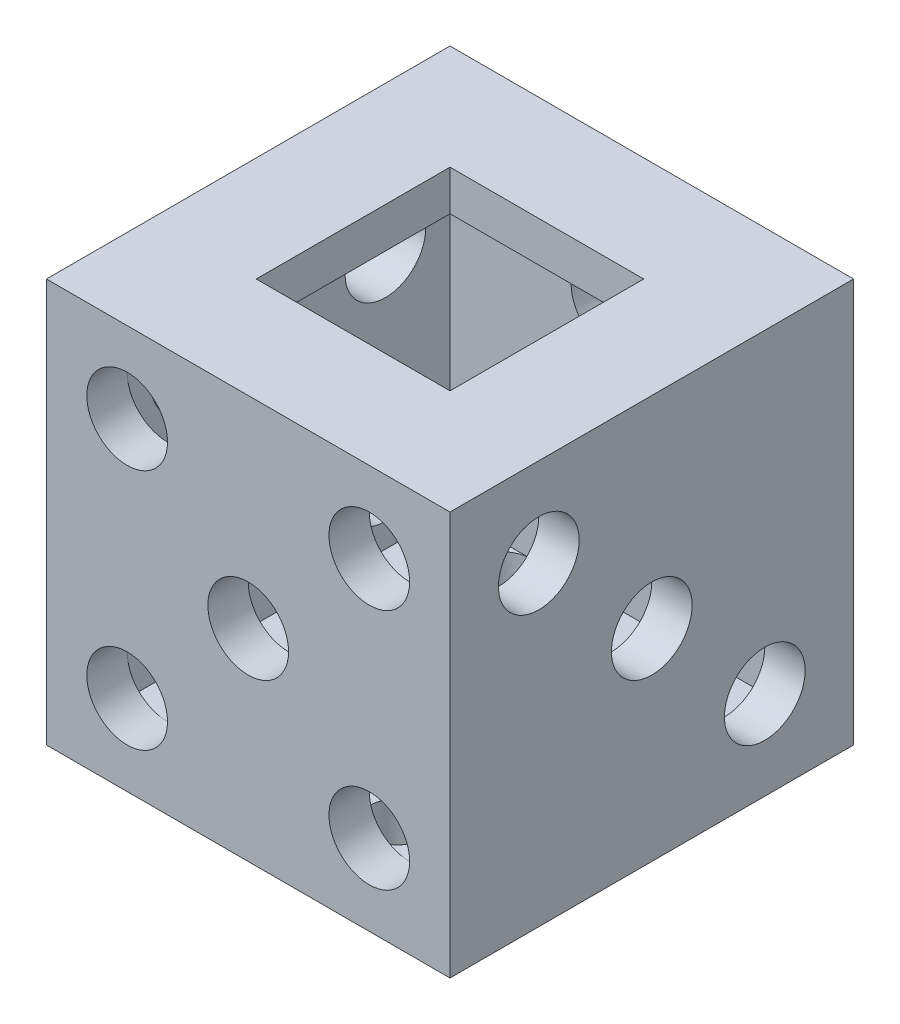
from build123d import *

# Parameters (mm, degrees)
SKETCH1_W           = 25
SKETCH1_H           = 25
BOSS_EXTRUDE1_DEPTH = 25
SHELL1_T            = 2.5
SKETCH2_W           = 12
SKETCH2_H           = 12
CUT_EXTRUDE1_DEPTH  = 15
SKETCH3_R           = 1.75
CUT_EXTRUDE2_DEPTH  = 15
SKETCH4_R           = 2.5
CUT_EXTRUDE6_DEPTH  = 15
SKETCH4_3_R         = 2.5
CUT_EXTRUDE7_DEPTH  = 15
SKETCH5_R           = 2.5
CUT_EXTRUDE8_DEPTH  = 15
SKETCH5_4_R         = 2.5
CUT_EXTRUDE9_DEPTH  = 15
SKETCH5_5_R         = 2.5
CUT_EXTRUDE10_DEPTH = 15
SKETCH7_R           = 2.5
CUT_EXTRUDE11_DEPTH = 15
SKETCH8_R           = 2.5
CUT_EXTRUDE12_DEPTH = 10


with BuildPart() as part:
    # Sketch1 → Boss-Extrude1 (new body)
    with BuildSketch(Plane(origin=(0, 0, 0), x_dir=(1, 0, 0), z_dir=(0, 1, 0))):
        Rectangle(SKETCH1_W, SKETCH1_H)
    extrude(amount=BOSS_EXTRUDE1_DEPTH)

    # Shell1 (no face opened: a closed hollow body)
    add(offset(amount=-SHELL1_T, mode=Mode.PRIVATE), mode=Mode.SUBTRACT)

    # Sketch2 → Cut-Extrude1 (cut)
    with BuildSketch(Plane(origin=(0, 25, 0), x_dir=(1, 0, 0), z_dir=(0, 1, 0))):
        Rectangle(SKETCH2_W, SKETCH2_H)
    extrude(amount=-CUT_EXTRUDE1_DEPTH, mode=Mode.SUBTRACT)

    # Sketch3 → Cut-Extrude2 (cut)
    with BuildSketch(Plane.XZ):
        with Locations((-5, 8.25)):
            Circle(SKETCH3_R)
        with Locations((-5, 0)):
            Circle(SKETCH3_R)
        with Locations((-5, -8.25)):
            Circle(SKETCH3_R)
        with Locations((5, 8.25)):
            Circle(SKETCH3_R)
        with Locations((5, 0)):
            Circle(SKETCH3_R)
        with Locations((5, -8.25)):
            Circle(SKETCH3_R)
    extrude(amount=-CUT_EXTRUDE2_DEPTH, mode=Mode.SUBTRACT)

    # Sketch4 → Cut-Extrude6 (cut)
    with BuildSketch(Plane(origin=(12.5, 0, 0), x_dir=(0, 0, -1), z_dir=(1, 0, 0))):
        with Locations((-7, 19.5)):
            Circle(SKETCH4_R)
    extrude(amount=-CUT_EXTRUDE6_DEPTH, mode=Mode.SUBTRACT)

    # Sketch4_3 → Cut-Extrude7 (cut)
    with BuildSketch(Plane(origin=(12.5, 0, 0), x_dir=(0, 0, -1), z_dir=(1, 0, 0))):
        with Locations((0, 12.5)):
            Circle(SKETCH4_3_R)
        with Locations((7, 5.5)):
            Circle(SKETCH4_3_R)
    extrude(amount=-CUT_EXTRUDE7_DEPTH, mode=Mode.SUBTRACT)

    # Sketch5 → Cut-Extrude8 (cut)
    with BuildSketch(Plane.ZY.offset(12.5)):
        with Locations((-6, 18.5)):
            Circle(SKETCH5_R)
    extrude(amount=-CUT_EXTRUDE8_DEPTH, mode=Mode.SUBTRACT)

    # Sketch5_4 → Cut-Extrude9 (cut)
    with BuildSketch(Plane.ZY.offset(12.5)):
        with Locations((6, 18.5)):
            Circle(SKETCH5_4_R)
    extrude(amount=-CUT_EXTRUDE9_DEPTH, mode=Mode.SUBTRACT)

    # Sketch5_5 → Cut-Extrude10 (cut)
    with BuildSketch(Plane.ZY.offset(12.5)):
        with Locations((6, 6.5)):
            Circle(SKETCH5_5_R)
        with Locations((-6, 6.5)):
            Circle(SKETCH5_5_R)
    extrude(amount=-CUT_EXTRUDE10_DEPTH, mode=Mode.SUBTRACT)

    # Sketch7 → Cut-Extrude11 (cut)
    with BuildSketch(Plane.XY.offset(12.5)):
        with Locations((-7.5, 20)):
            Circle(SKETCH7_R)
        with Locations((0, 12.5)):
            Circle(SKETCH7_R)
        with Locations((7.5, 20)):
            Circle(SKETCH7_R)
        with Locations((7.5, 5)):
            Circle(SKETCH7_R)
        with Locations((-7.5, 5)):
            Circle(SKETCH7_R)
    extrude(amount=-CUT_EXTRUDE11_DEPTH, mode=Mode.SUBTRACT)

    # Sketch8 → Cut-Extrude12 (cut)
    with BuildSketch(Plane(origin=(0, 0, -12.5), x_dir=(-1, 0, 0), z_dir=(0, 0, -1))):
        with Locations((0, 18.5)):
            Circle(SKETCH8_R)
        with Locations((0, 6.5)):
            Circle(SKETCH8_R)
    extrude(amount=-CUT_EXTRUDE12_DEPTH, mode=Mode.SUBTRACT)


solid = part.part
